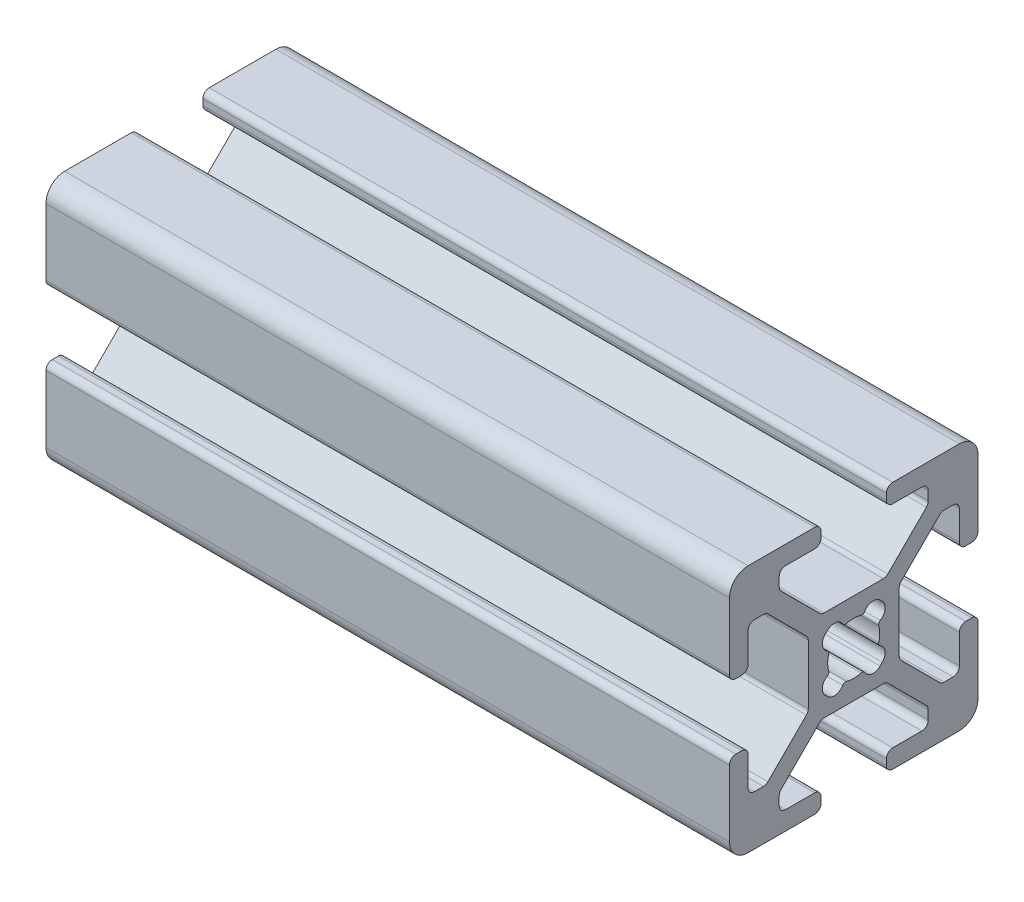
from build123d import *

# Parameters (mm, degrees)
F_20_SERIES_20_2020_1_DEPTH = 55


with BuildPart() as part:
    # Sketch11 → 20_series 20-2020(1) (new body)
    with BuildSketch(Plane(origin=(0, 0, 0), x_dir=(0, 0, -1), z_dir=(1, 0, 0))):
        with BuildLine():
            Line((9.0094, 2.6289), (9.492, 2.6289))
            ThreePointArc((9.492, 2.6289), (9.851210245, 2.777689755), (10, 3.1369))
            Line((10, 3.1369), (10, 8.5014))
            ThreePointArc((10, 8.5014), (9.561070222, 9.561070222), (8.5014, 10))
            Line((8.5014, 10), (3.1369, 10))
            ThreePointArc((3.1369, 10), (2.777689755, 9.851210245), (2.6289, 9.492))
            Line((2.6289, 9.492), (2.6289, 9.0094))
            ThreePointArc((2.6289, 9.0094), (2.777689755, 8.650189755), (3.1369, 8.5014))
            Line((3.1369, 8.5014), (5.4864, 8.5014))
            ThreePointArc((5.4864, 8.5014), (5.845610245, 8.352610245), (5.9944, 7.9934))
            Line((5.9944, 7.9934), (5.9944, 7.264490712))
            ThreePointArc((5.9944, 7.264490712), (5.955730803, 7.070087528), (5.845610245, 6.905280467))
            Line((5.845610245, 6.905280467), (2.747686782, 3.807357004))
            ThreePointArc((2.747686782, 3.807357004), (2.582879721, 3.697236446), (2.388476537, 3.658567249))
            Line((2.388476537, 3.658567249), (-2.388476537, 3.658567249))
            ThreePointArc((-2.388476537, 3.658567249), (-2.582879721, 3.697236446), (-2.747686782, 3.807357004))
            Line((-2.747686782, 3.807357004), (-5.845610245, 6.905280467))
            ThreePointArc((-5.845610245, 6.905280467), (-5.955730803, 7.070087528), (-5.9944, 7.264490712))
            Line((-5.9944, 7.264490712), (-5.9944, 7.9934))
            ThreePointArc((-5.9944, 7.9934), (-5.845610245, 8.352610245), (-5.4864, 8.5014))
            Line((-5.4864, 8.5014), (-3.1369, 8.5014))
            ThreePointArc((-3.1369, 8.5014), (-2.777689755, 8.650189755), (-2.6289, 9.0094))
            Line((-2.6289, 9.0094), (-2.6289, 9.492))
            ThreePointArc((-2.6289, 9.492), (-2.777689755, 9.851210245), (-3.1369, 10))
            Line((-3.1369, 10), (-8.5014, 10))
            ThreePointArc((-8.5014, 10), (-9.561070222, 9.561070222), (-10, 8.5014))
            Line((-10, 8.5014), (-10, 3.1369))
            ThreePointArc((-10, 3.1369), (-9.851210245, 2.777689755), (-9.492, 2.6289))
            Line((-9.492, 2.6289), (-9.0094, 2.6289))
            ThreePointArc((-9.0094, 2.6289), (-8.650189755, 2.777689755), (-8.5014, 3.1369))
            Line((-8.5014, 3.1369), (-8.5014, 5.4864))
            ThreePointArc((-8.5014, 5.4864), (-8.352610245, 5.845610245), (-7.9934, 5.9944))
            Line((-7.9934, 5.9944), (-7.264490712, 5.9944))
            ThreePointArc((-7.264490712, 5.9944), (-7.070087528, 5.955730803), (-6.905280467, 5.845610245))
            Line((-6.905280467, 5.845610245), (-3.807357004, 2.747686782))
            ThreePointArc((-3.807357004, 2.747686782), (-3.697236446, 2.582879721), (-3.658567249, 2.388476537))
            Line((-3.658567249, 2.388476537), (-3.658567249, -2.388476537))
            ThreePointArc((-3.658567249, -2.388476537), (-3.697236446, -2.582879721), (-3.807357004, -2.747686782))
            Line((-3.807357004, -2.747686782), (-6.905280467, -5.845610245))
            ThreePointArc((-6.905280467, -5.845610245), (-7.070087528, -5.955730803), (-7.264490712, -5.9944))
            Line((-7.264490712, -5.9944), (-7.9934, -5.9944))
            ThreePointArc((-7.9934, -5.9944), (-8.352610245, -5.845610245), (-8.5014, -5.4864))
            Line((-8.5014, -5.4864), (-8.5014, -3.1369))
            ThreePointArc((-8.5014, -3.1369), (-8.650189755, -2.777689755), (-9.0094, -2.6289))
            Line((-9.0094, -2.6289), (-9.492, -2.6289))
            ThreePointArc((-9.492, -2.6289), (-9.851210245, -2.777689755), (-10, -3.1369))
            Line((-10, -3.1369), (-10, -8.5014))
            ThreePointArc((-10, -8.5014), (-9.561070222, -9.561070222), (-8.5014, -10))
            Line((-8.5014, -10), (-3.1369, -10))
            ThreePointArc((-3.1369, -10), (-2.777689755, -9.851210245), (-2.6289, -9.492))
            Line((-2.6289, -9.492), (-2.6289, -9.0094))
            ThreePointArc((-2.6289, -9.0094), (-2.777689755, -8.650189755), (-3.1369, -8.5014))
            Line((-3.1369, -8.5014), (-5.4864, -8.5014))
            ThreePointArc((-5.4864, -8.5014), (-5.845610245, -8.352610245), (-5.9944, -7.9934))
            Line((-5.9944, -7.9934), (-5.9944, -7.264490712))
            ThreePointArc((-5.9944, -7.264490712), (-5.955730803, -7.070087528), (-5.845610245, -6.905280467))
            Line((-5.845610245, -6.905280467), (-2.747686782, -3.807357004))
            ThreePointArc((-2.747686782, -3.807357004), (-2.582879721, -3.697236446), (-2.388476537, -3.658567249))
            Line((-2.388476537, -3.658567249), (2.388476537, -3.658567249))
            ThreePointArc((2.388476537, -3.658567249), (2.582879721, -3.697236446), (2.747686782, -3.807357004))
            Line((2.747686782, -3.807357004), (5.845610245, -6.905280467))
            ThreePointArc((5.845610245, -6.905280467), (5.955730803, -7.070087528), (5.9944, -7.264490712))
            Line((5.9944, -7.264490712), (5.9944, -7.9934))
            ThreePointArc((5.9944, -7.9934), (5.845610245, -8.352610245), (5.4864, -8.5014))
            Line((5.4864, -8.5014), (3.1369, -8.5014))
            ThreePointArc((3.1369, -8.5014), (2.777689755, -8.650189755), (2.6289, -9.0094))
            Line((2.6289, -9.0094), (2.6289, -9.492))
            ThreePointArc((2.6289, -9.492), (2.777689755, -9.851210245), (3.1369, -10))
            Line((3.1369, -10), (8.5014, -10))
            ThreePointArc((8.5014, -10), (9.561070222, -9.561070222), (10, -8.5014))
            Line((10, -8.5014), (10, -3.1369))
            ThreePointArc((10, -3.1369), (9.851210245, -2.777689755), (9.492, -2.6289))
            Line((9.492, -2.6289), (9.0094, -2.6289))
            ThreePointArc((9.0094, -2.6289), (8.650189755, -2.777689755), (8.5014, -3.1369))
            Line((8.5014, -3.1369), (8.5014, -5.4864))
            ThreePointArc((8.5014, -5.4864), (8.352610245, -5.845610245), (7.9934, -5.9944))
            Line((7.9934, -5.9944), (7.264490712, -5.9944))
            ThreePointArc((7.264490712, -5.9944), (7.070087528, -5.955730803), (6.905280467, -5.845610245))
            Line((6.905280467, -5.845610245), (3.807357004, -2.747686782))
            ThreePointArc((3.807357004, -2.747686782), (3.697236446, -2.582879721), (3.658567249, -2.388476537))
            Line((3.658567249, -2.388476537), (3.658567249, 2.388476537))
            ThreePointArc((3.658567249, 2.388476537), (3.697236446, 2.582879721), (3.807357004, 2.747686782))
            Line((3.807357004, 2.747686782), (6.905280467, 5.845610245))
            ThreePointArc((6.905280467, 5.845610245), (7.070087528, 5.955730803), (7.264490712, 5.9944))
            Line((7.264490712, 5.9944), (7.9934, 5.9944))
            ThreePointArc((7.9934, 5.9944), (8.352610245, 5.845610245), (8.5014, 5.4864))
            Line((8.5014, 5.4864), (8.5014, 3.1369))
            ThreePointArc((8.5014, 3.1369), (8.650189755, 2.777689755), (9.0094, 2.6289))
        make_face()
        with BuildLine():
            Line((-2.296558466, 2.121727546), (-2.121727546, 2.296558466))
            ThreePointArc((-2.121727546, 2.296558466), (-1.459775814, 2.520126613), (-0.880635441, 2.129282347))
            ThreePointArc((-0.880635441, 2.129282347), (-0.755121693, 2.019456424), (-0.588548999, 2.011151493))
            ThreePointArc((-0.588548999, 2.011151493), (0, 2.0955), (0.588548999, 2.011151493))
            ThreePointArc((0.588548999, 2.011151493), (0.755121693, 2.019456424), (0.880635441, 2.129282347))
            ThreePointArc((0.880635441, 2.129282347), (1.459775814, 2.520126613), (2.121727546, 2.296558466))
            Line((2.121727546, 2.296558466), (2.296558466, 2.121727546))
            ThreePointArc((2.296558466, 2.121727546), (2.520126613, 1.459775814), (2.129282347, 0.880635441))
            ThreePointArc((2.129282347, 0.880635441), (2.019456424, 0.755121693), (2.011151493, 0.588548999))
            ThreePointArc((2.011151493, 0.588548999), (2.0955, 0), (2.011151493, -0.588548999))
            ThreePointArc((2.011151493, -0.588548999), (2.019456424, -0.755121693), (2.129282347, -0.880635441))
            ThreePointArc((2.129282347, -0.880635441), (2.520126613, -1.459775814), (2.296558466, -2.121727546))
            Line((2.296558466, -2.121727546), (2.121727546, -2.296558466))
            ThreePointArc((2.121727546, -2.296558466), (1.459775814, -2.520126613), (0.880635441, -2.129282347))
            ThreePointArc((0.880635441, -2.129282347), (0.755121693, -2.019456424), (0.588548999, -2.011151493))
            ThreePointArc((0.588548999, -2.011151493), (0, -2.0955), (-0.588548999, -2.011151493))
            ThreePointArc((-0.588548999, -2.011151493), (-0.755121693, -2.019456424), (-0.880635441, -2.129282347))
            ThreePointArc((-0.880635441, -2.129282347), (-1.459775814, -2.520126613), (-2.121727546, -2.296558466))
            Line((-2.121727546, -2.296558466), (-2.296558466, -2.121727546))
            ThreePointArc((-2.296558466, -2.121727546), (-2.520126613, -1.459775814), (-2.129282347, -0.880635441))
            ThreePointArc((-2.129282347, -0.880635441), (-2.019456424, -0.755121693), (-2.011151493, -0.588548999))
            ThreePointArc((-2.011151493, -0.588548999), (-2.0955, 0), (-2.011151493, 0.588548999))
            ThreePointArc((-2.011151493, 0.588548999), (-2.019456424, 0.755121693), (-2.129282347, 0.880635441))
            ThreePointArc((-2.129282347, 0.880635441), (-2.520126613, 1.459775814), (-2.296558466, 2.121727546))
        make_face(mode=Mode.SUBTRACT)
    extrude(amount=F_20_SERIES_20_2020_1_DEPTH)


solid = part.part
